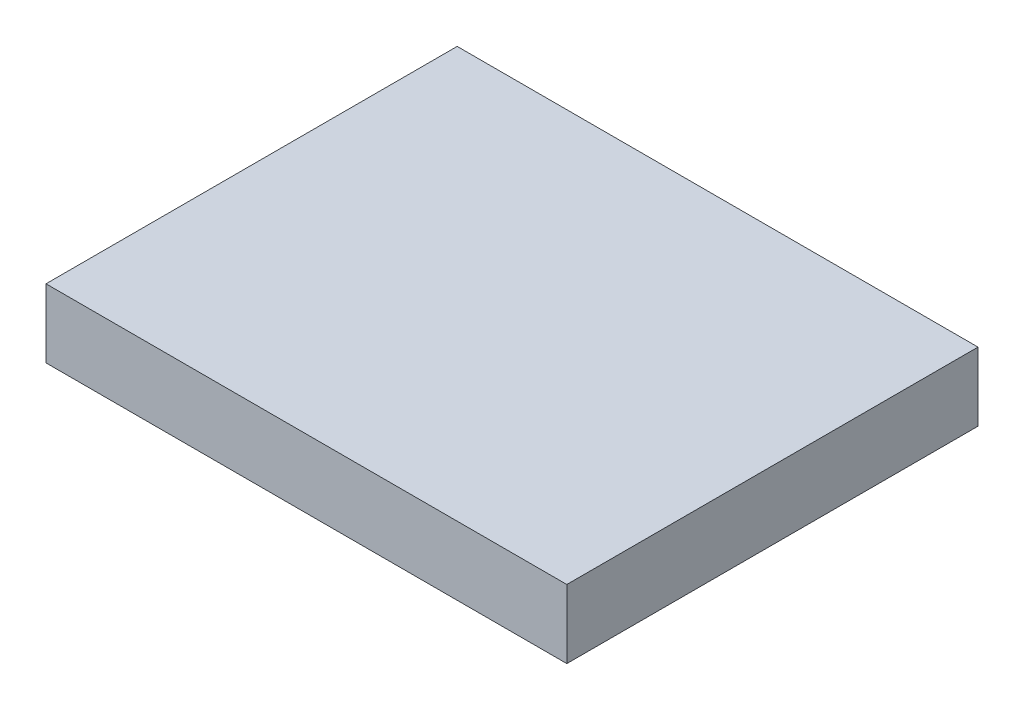
from build123d import *

# Parameters (mm, degrees)
SKETCH1_W      = 19.304
SKETCH1_H      = 15.24
EXTRUDE1_DEPTH = 2.54


with BuildPart() as part:
    # Sketch1 → Extrude1 (new body)
    with BuildSketch(Plane(origin=(0, 0, 0), x_dir=(1, 0, 0), z_dir=(0, 1, 0))):
        Rectangle(SKETCH1_W, SKETCH1_H)
    extrude(amount=EXTRUDE1_DEPTH)


solid = part.part
